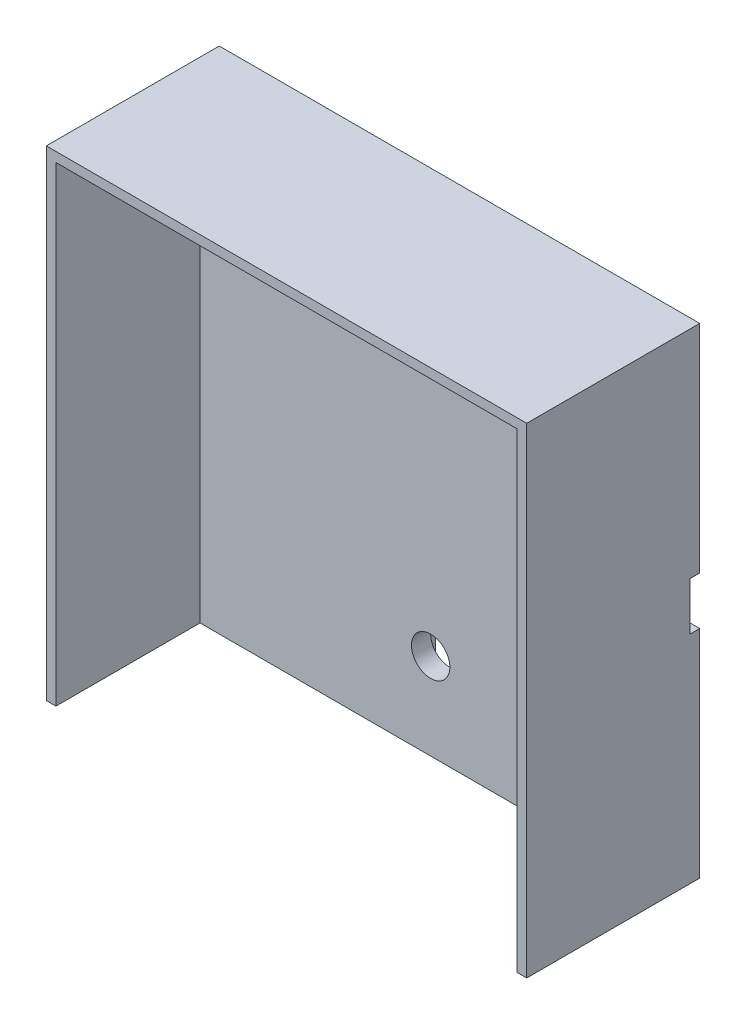
from build123d import *

# Parameters (mm, degrees)
SKICA1_W                 = 50
SKICA1_H                 = 50
P_IDAT_VYSUNUT_M2_DEPTH  = 3
SKICA5_W                 = 5
SKICA5_H                 = 22.5
ODEBRAT_VYSUNUT_M3_DEPTH = 1
P_IDAT_VYSUNUT_M9_DEPTH  = 15
SKICA17_R                = 2
ODEBRAT_VYSUNUT_M8_DEPTH = 4
ZAOBLIT1_R               = 10
ZAOBLIT2_R               = 5


with BuildPart() as part:
    # Skica1 → Přidat vysunutím2 (new body)
    with BuildSketch(Plane.XY):
        Rectangle(SKICA1_W, SKICA1_H)
    extrude(amount=P_IDAT_VYSUNUT_M2_DEPTH)

    # Skica5 → Odebrat vysunutím3 (cut)
    with BuildSketch(Plane(origin=(0, 0, 0), x_dir=(-1, 0, 0), z_dir=(0, 0, -1))):
        Polygon((-25, -2.5), (-2.5, -2.5), (2.5, -2.5), (2.5, 2.5), (-25, 2.5), align=None)
        with Locations((0, -13.75)):
            Rectangle(SKICA5_W, SKICA5_H)
    extrude(amount=-ODEBRAT_VYSUNUT_M3_DEPTH, mode=Mode.SUBTRACT)

    # Skica14 → Přidat vysunutím9 (add)
    with BuildSketch(Plane.XY.offset(3)):
        Polygon((25, 25), (-25, 25), (-25, -25), (-24, -25), (-24, 24), (24, 24), (24, -25), (25, -25), align=None)
    extrude(amount=P_IDAT_VYSUNUT_M9_DEPTH)

    # Skica17 → Odebrat vysunutím8 (cut)
    with BuildSketch(Plane(origin=(0, 0, 1), x_dir=(-1, 0, 0), z_dir=(0, 0, -1))):
        with Locations((-16, 0)):
            Circle(SKICA17_R)
        with Locations((0, -16)):
            Circle(SKICA17_R)
    extrude(amount=-ODEBRAT_VYSUNUT_M8_DEPTH, mode=Mode.SUBTRACT)

    # Zaoblit1
    zaoblit1_edges = [part.edges().sort_by_distance(p)[0] for p in [
        (-2.5, 2.5, 0.5),
    ]]
    fillet(zaoblit1_edges, radius=ZAOBLIT1_R)

    # Zaoblit2
    zaoblit2_edges = [part.edges().sort_by_distance(p)[0] for p in [
        (2.5, -2.5, 0.5),
    ]]
    fillet(zaoblit2_edges, radius=ZAOBLIT2_R)


solid = part.part
